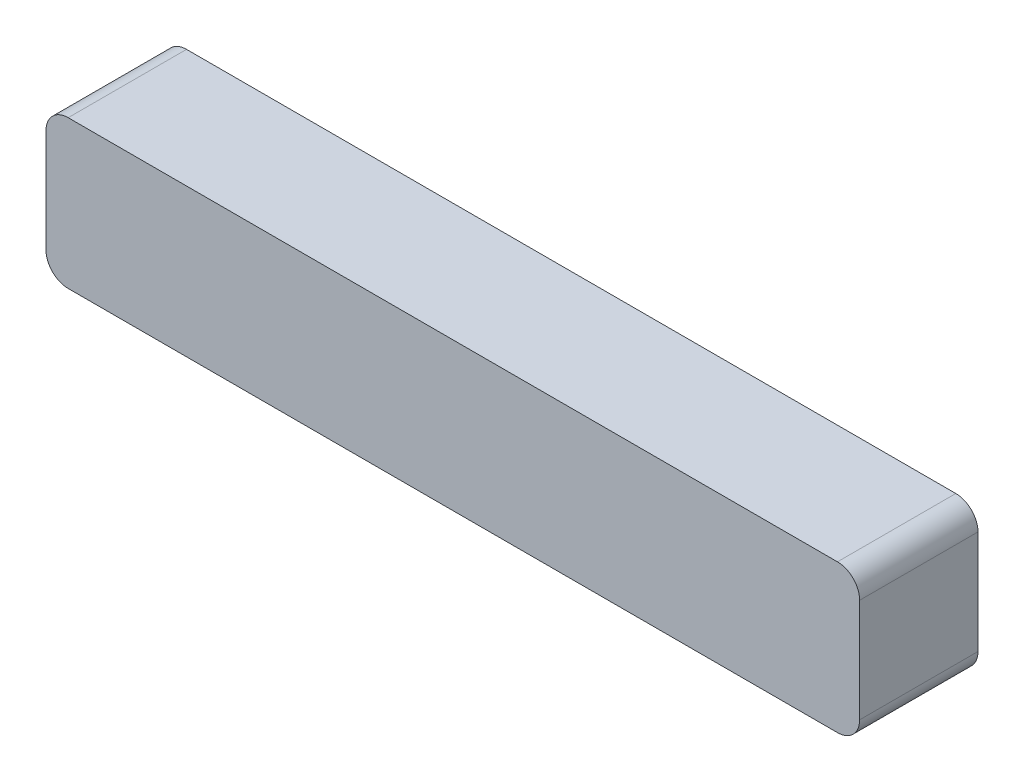
from build123d import *

# Parameters (mm, degrees)
EXTRUDE_1_DEPTH = 16


with BuildPart() as part:
    # 草图1 → 凸台-拉伸1 (new body)
    with BuildSketch(Plane.XY):
        with BuildLine():
            Line((3, 0), (107, 0))
            ThreePointArc((107, 0), (109.121320344, 0.878679656), (110, 3))
            Line((110, 3), (110, 17))
            ThreePointArc((110, 17), (109.121320344, 19.121320344), (107, 20))
            Line((107, 20), (3, 20))
            ThreePointArc((3, 20), (0.878679656, 19.121320344), (0, 17))
            Line((0, 17), (0, 3))
            ThreePointArc((0, 3), (0.878679656, 0.878679656), (3, 0))
        make_face()
    extrude(amount=EXTRUDE_1_DEPTH)


solid = part.part
